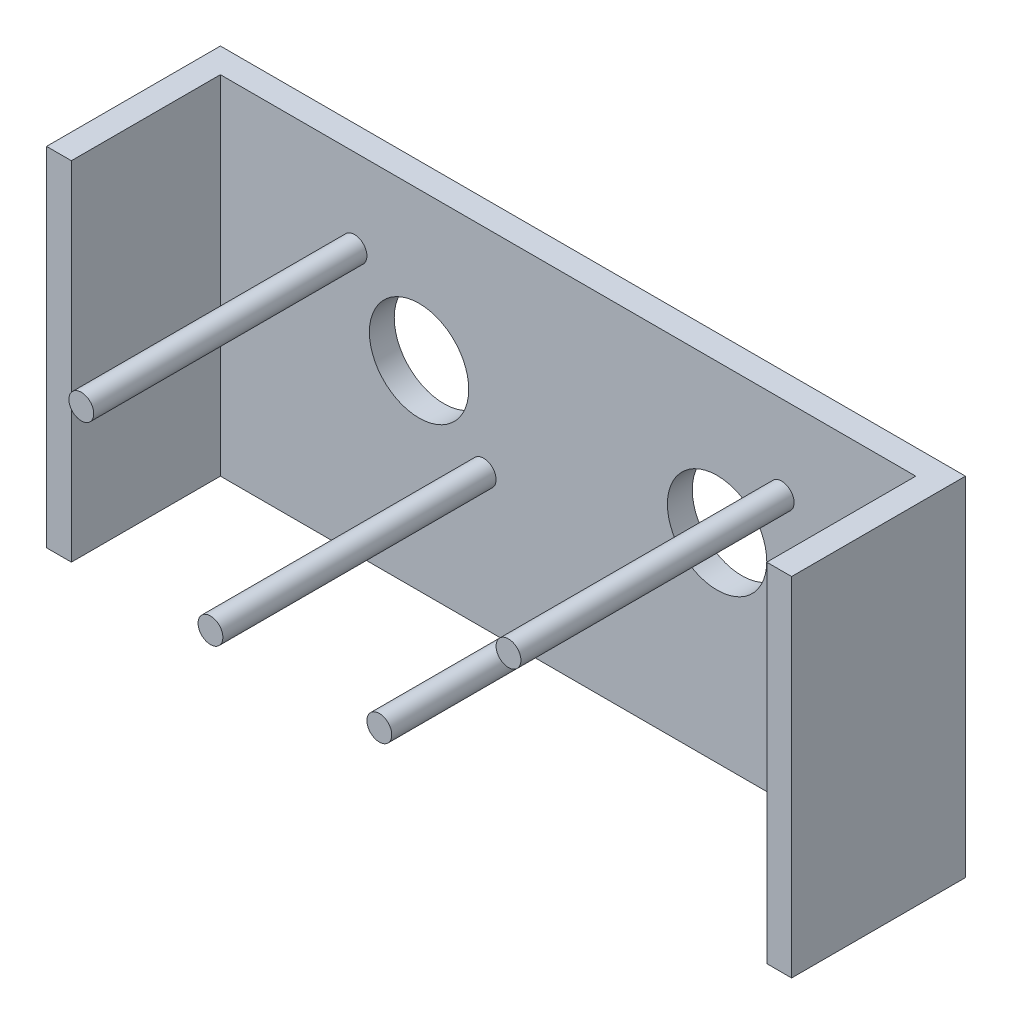
from build123d import *

# Parameters (mm, degrees)
ESQUISSE1_W             = 150
ESQUISSE1_H             = 70
BOSS_EXTRU_1_DEPTH      = 5
ESQUISSE2_W             = 5
ESQUISSE2_H             = 70
BOSS_EXTRU_2_DEPTH      = 30
ESQUISSE3_R             = 10
ENL_V_MAT_EXTRU_1_DEPTH = 30
ESQUISSE5_R             = 2.5
BOSS_EXTRU_3_DEPTH      = 60


with BuildPart() as part:
    # Esquisse1 → Boss.-Extru.1 (new body)
    with BuildSketch(Plane.XY):
        with Locations((8.080821687, -0.482695652)):
            Rectangle(ESQUISSE1_W, ESQUISSE1_H)
    extrude(amount=BOSS_EXTRU_1_DEPTH)

    # Esquisse2 → Boss.-Extru.2 (add)
    with BuildSketch(Plane.XY.offset(5)):
        with Locations((-64.419178313, -0.482695652)):
            Rectangle(ESQUISSE2_W, ESQUISSE2_H)
        with Locations((80.580821687, -0.482695652)):
            Rectangle(ESQUISSE2_W, ESQUISSE2_H)
    extrude(amount=BOSS_EXTRU_2_DEPTH)

    # Esquisse3 → Enlèv. mat.-Extru.1 (cut)
    with BuildSketch(Plane(origin=(0, 0, 0), x_dir=(-1, 0, 0), z_dir=(0, 0, -1))):
        with Locations((21.919178313, 4.647304348)):
            Circle(ESQUISSE3_R)
        with Locations((-38.080821687, 4.647304348)):
            Circle(ESQUISSE3_R)
    extrude(amount=-ENL_V_MAT_EXTRU_1_DEPTH, mode=Mode.SUBTRACT)

    # Esquisse5 → Boss.-Extru.3 (add)
    with BuildSketch(Plane(origin=(0, 0, 0), x_dir=(-1, 0, 0), z_dir=(0, 0, -1))):
        with Locations((34.919178313, 17.647304348)):
            Circle(ESQUISSE5_R)
        with Locations((8.919178313, -8.352695652)):
            Circle(ESQUISSE5_R)
        with Locations((-51.080821687, 17.647304348)):
            Circle(ESQUISSE5_R)
        with Locations((-25.080821687, -8.352695652)):
            Circle(ESQUISSE5_R)
    extrude(amount=-BOSS_EXTRU_3_DEPTH)


solid = part.part
